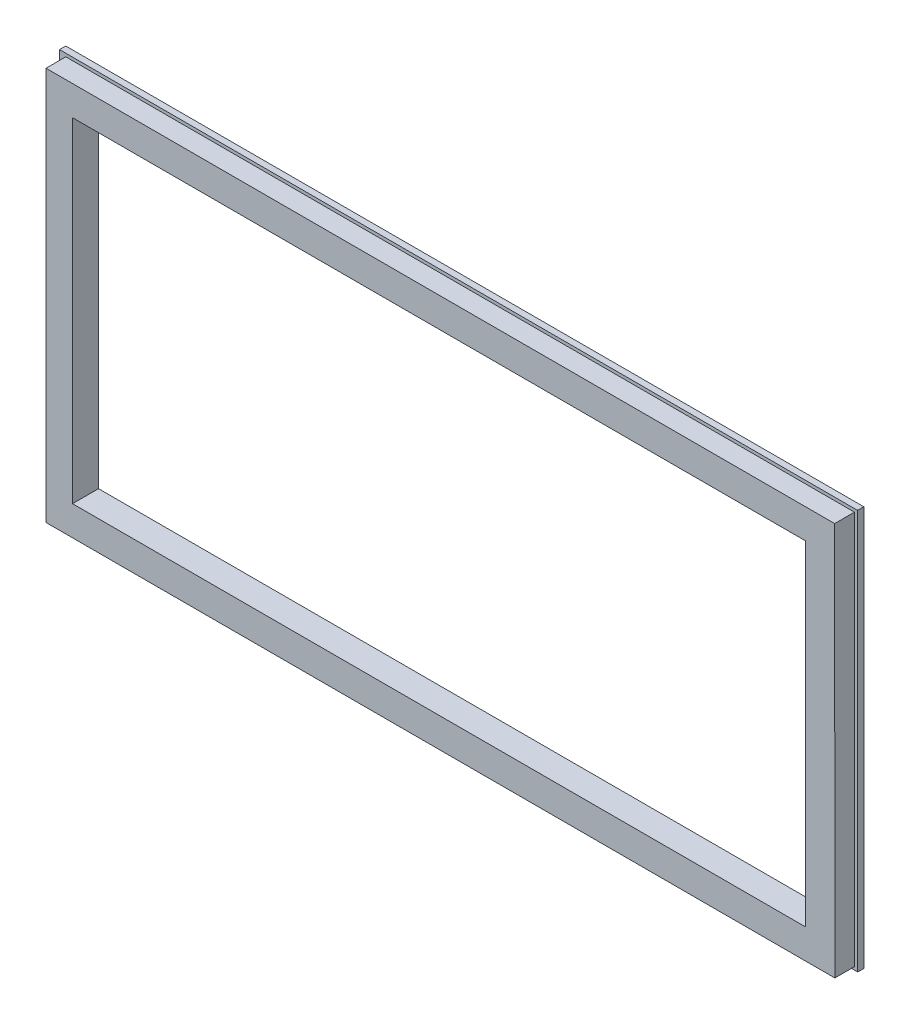
from build123d import *

# Parameters (mm, degrees)
EXTRUDE_1_DEPTH       = 16
CUT_EXTRUDE_1_DEPTH   = 13
CUT_EXTRUDE_1_2_DEPTH = 3.5
CUT_EXTRUDE_2_DEPTH   = 14.5


with BuildPart() as part:
    # Model → 凸台-拉伸1 (new body)
    with BuildSketch(Plane.XY):
        Polygon((-7.935386074, 184.294), (-7.904930268, -7.726795577), (375.566, -7.74368854), (375.473711158, 184.294), align=None)
    extrude(amount=EXTRUDE_1_DEPTH)

    # 草图3 → Cut-Extrude 1 (cut)
    # profile 1 of 2: a face of its own
    with BuildSketch(Plane.XY.offset(16)):
        Polygon((-6.404930287, -7.726557667), (-6.435386093, 184.29423791), (-4.935386112, 184.29447582), (-4.904930306, -7.726319757), align=None)
    # profile 2 of 2: a face of its own
    with BuildSketch(Plane.XY.offset(16)):
        Polygon((375.473711158, 184.294), (-7.935386074, 184.294), (-7.904930268, -7.726795577), (375.566, -7.74368854), align=None)
        Polygon((373.97443185, 182.794), (-6.435148145, 182.794), (-6.405168149, -6.226861644), (374.06527893, -6.243622428), align=None, mode=Mode.SUBTRACT)
    extrude(amount=-CUT_EXTRUDE_1_DEPTH, mode=Mode.SUBTRACT)

    # 草图3<5> → Cut-Extrude 1 2 (cut)
    with BuildSketch(Plane.XY.offset(16)):
        Polygon((-6.435148145, 182.794), (-6.405168149, -6.226861644), (374.06527893, -6.243622428), (373.97443185, 182.794), align=None)
    extrude(amount=-CUT_EXTRUDE_1_2_DEPTH, mode=Mode.SUBTRACT)

    # 草图4 → 切除-拉伸2 (cut)
    with BuildSketch(Plane.XY.offset(12.5)):
        Polygon((7.7946046, 7.972254), (359.86752, 7.972254), (359.870508087, 168.593), (7.787335087, 168.593), align=None)
    extrude(amount=-CUT_EXTRUDE_2_DEPTH, mode=Mode.SUBTRACT)


solid = part.part
